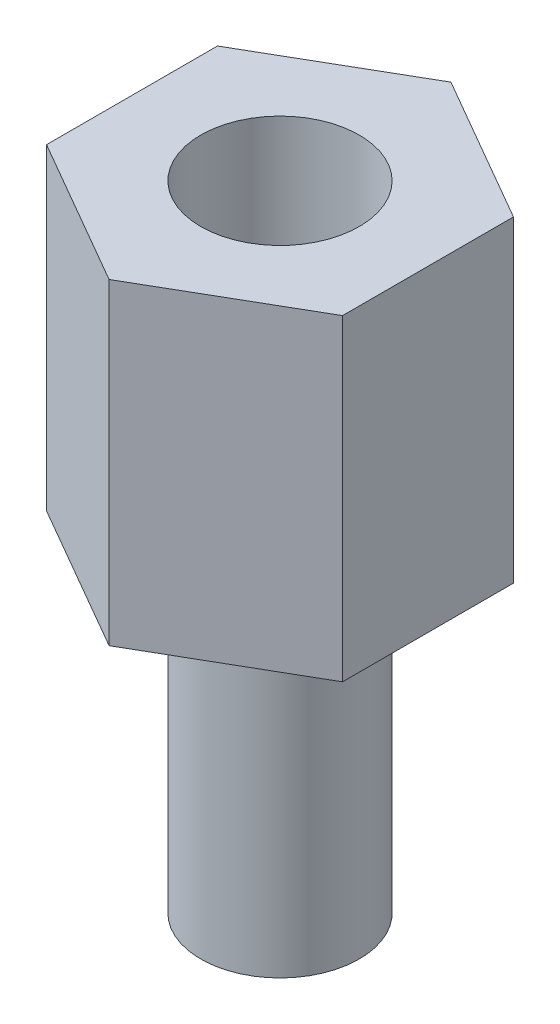
from build123d import *

# Parameters (mm, degrees)
BOSS_EXTRUDE1_DEPTH = 6
SKETCH2_R           = 1.5
BOSS_EXTRUDE2_DEPTH = 6
SKETCH3_R           = 1.5
CUT_EXTRUDE1_DEPTH  = 4


with BuildPart() as part:
    # Sketch1 → Boss-Extrude1 (new body)
    with BuildSketch(Plane(origin=(0, 0, 0), x_dir=(1, 0, 0), z_dir=(0, 1, 0))):
        Polygon((0, -3.233161507), (2.8, -1.616580754), (2.8, 1.616580754), (0, 3.233161507), (-2.8, 1.616580754), (-2.8, -1.616580754), align=None)
    extrude(amount=BOSS_EXTRUDE1_DEPTH)

    # Sketch2 → Boss-Extrude2 (add)
    with BuildSketch(Plane(origin=(0, 0, 0), x_dir=(-1, 0, 0), z_dir=(0, -1, 0))):
        Circle(SKETCH2_R)
    extrude(amount=BOSS_EXTRUDE2_DEPTH)

    # Sketch3 → Cut-Extrude1 (cut)
    with BuildSketch(Plane(origin=(0, 6, 0), x_dir=(1, 0, 0), z_dir=(0, 1, 0))):
        Circle(SKETCH3_R)
    extrude(amount=-CUT_EXTRUDE1_DEPTH, mode=Mode.SUBTRACT)


solid = part.part
